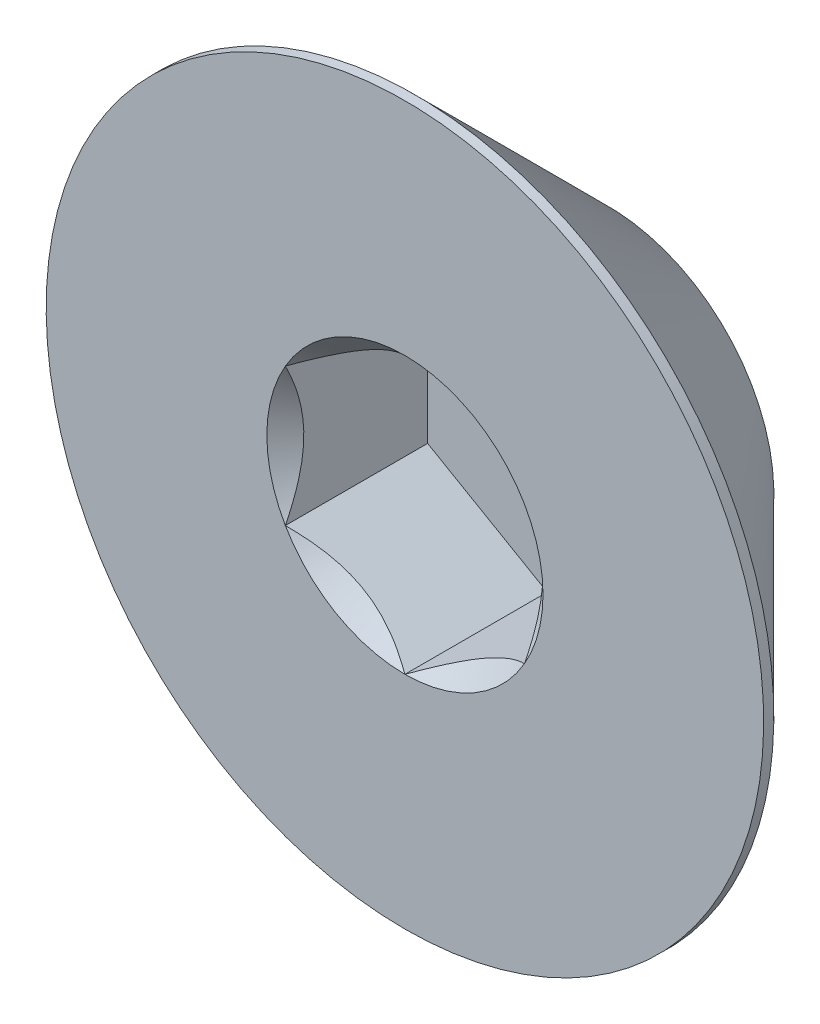
from build123d import *

# Parameters (mm, degrees)
CUT_EXTRUDE2_DEPTH = 1.19


with BuildPart() as part:
    # Sketch7 → Revolve2 (revolve)
    with BuildSketch(Plane(origin=(0, 0, 0), x_dir=(0, 0, -1), z_dir=(1, 0, 0)), mode=Mode.PRIVATE) as revolve2_sk:
        Polygon((-3, 3), (-2.915, 3), (-1.3, 1.385), (-1.3, 0), (-3, 0), align=None)
    revolve(revolve2_sk.sketch.rotate(Axis((0, 0, 3), (0, 0, -1)), 180), axis=Axis((0, 0, 3), (0, 0, -1)))

    # Sketch5 → Cut-Extrude2 (cut)
    with BuildSketch(Plane.XY.offset(3)):
        Polygon((1, -0.577350269), (1, 0.577350269), (0, 1.154700538), (-1, 0.577350269), (-1, -0.577350269), (0, -1.154700538), align=None)
    extrude(amount=-CUT_EXTRUDE2_DEPTH, mode=Mode.SUBTRACT)

    # Cut-Extrude3 cone 1 section (through the dimple's axis) → Cut-Extrude3 (revolve, cut)
    with BuildSketch(Plane(origin=(0, 0, 3), x_dir=(0, -1, 0), z_dir=(1, 0, 0))):
        Polygon((0, 0), (1.154700538, 0), (0, 1.154700538), align=None)
    revolve(axis=Axis((0, 0, 3), (0, 0, -1)), mode=Mode.SUBTRACT)


solid = part.part
